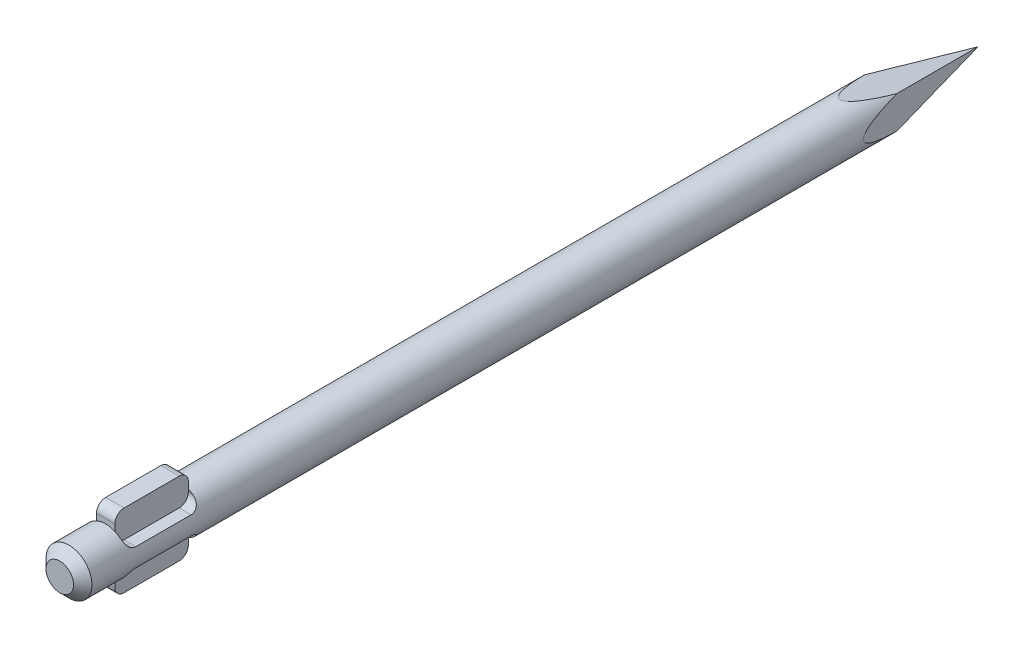
from build123d import *

# Parameters (mm, degrees)
SKETCH1_R           = 2.5
BOSS_EXTRUDE1_DEPTH = 100
CUT_EXTRUDE1_DEPTH  = 2.5
BOSS_EXTRUDE2_DEPTH = 1
CHAMFER1_SIZE       = 1
CUT_EXTRUDE2_DEPTH  = 2.5
CUT_EXTRUDE3_DEPTH  = 2.5


with BuildPart() as part:
    # Sketch1 → Boss-Extrude1 (new body)
    with BuildSketch(Plane.XY):
        Circle(SKETCH1_R)
    extrude(amount=BOSS_EXTRUDE1_DEPTH)

    # Sketch2 → Cut-Extrude1 (cut, symmetric)
    with BuildSketch(Plane(origin=(0, 0, 0), x_dir=(0, 0, -1), z_dir=(1, 0, 0))):
        with BuildLine():
            Line((-94, 4), (-88, 4))
            ThreePointArc((-88, 4), (-87.292893219, 3.707106781), (-87, 3))
            Line((-87, 3), (-87, 2))
            ThreePointArc((-87, 2), (-87.292893219, 1.292893219), (-88, 1))
            Line((-88, 1), (-94, 1))
            ThreePointArc((-94, 1), (-94.707106781, 1.292893219), (-95, 2))
            Line((-95, 2), (-95, 3))
            ThreePointArc((-95, 3), (-94.707106781, 3.707106781), (-94, 4))
        make_face()
        with BuildLine():
            Line((-95, -3), (-95, -2))
            ThreePointArc((-95, -2), (-94.707106781, -1.292893219), (-94, -1))
            Line((-94, -1), (-88, -1))
            ThreePointArc((-88, -1), (-87.292893219, -1.292893219), (-87, -2))
            Line((-87, -2), (-87, -3))
            ThreePointArc((-87, -3), (-87.292893219, -3.707106781), (-88, -4))
            Line((-88, -4), (-94, -4))
            ThreePointArc((-94, -4), (-94.707106781, -3.707106781), (-95, -3))
        make_face()
    extrude(amount=CUT_EXTRUDE1_DEPTH, both=True, mode=Mode.SUBTRACT)

    # Sketch2_2 → Boss-Extrude2 (add, symmetric)
    with BuildSketch(Plane(origin=(0, 0, 0), x_dir=(0, 0, -1), z_dir=(1, 0, 0))):
        with BuildLine():
            Line((-94, 4), (-88, 4))
            ThreePointArc((-88, 4), (-87.292893219, 3.707106781), (-87, 3))
            Line((-87, 3), (-87, 2))
            ThreePointArc((-87, 2), (-87.292893219, 1.292893219), (-88, 1))
            Line((-88, 1), (-94, 1))
            ThreePointArc((-94, 1), (-94.707106781, 1.292893219), (-95, 2))
            Line((-95, 2), (-95, 3))
            ThreePointArc((-95, 3), (-94.707106781, 3.707106781), (-94, 4))
        make_face()
        with BuildLine():
            Line((-95, -3), (-95, -2))
            ThreePointArc((-95, -2), (-94.707106781, -1.292893219), (-94, -1))
            Line((-94, -1), (-88, -1))
            ThreePointArc((-88, -1), (-87.292893219, -1.292893219), (-87, -2))
            Line((-87, -2), (-87, -3))
            ThreePointArc((-87, -3), (-87.292893219, -3.707106781), (-88, -4))
            Line((-88, -4), (-94, -4))
            ThreePointArc((-94, -4), (-94.707106781, -3.707106781), (-95, -3))
        make_face()
    extrude(amount=BOSS_EXTRUDE2_DEPTH, both=True)

    # Chamfer1
    chamfer1_edges = [part.edges().sort_by_distance(p)[0] for p in [
        (-2.5, 0, 100),
    ]]
    chamfer(chamfer1_edges, length=CHAMFER1_SIZE)

    # Sketch3 → Cut-Extrude2 (cut, symmetric)
    with BuildSketch(Plane(origin=(0, 0, 0), x_dir=(0, 0, -1), z_dir=(1, 0, 0))):
        Polygon((0, -2.5), (0, 0), (-15, -2.5), align=None)
        Polygon((-15, 2.5), (0, 0), (0, 2.5), align=None)
    extrude(amount=CUT_EXTRUDE2_DEPTH, both=True, mode=Mode.SUBTRACT)

    # Sketch4 → Cut-Extrude3 (cut, symmetric)
    with BuildSketch(Plane(origin=(0, 0, 0), x_dir=(1, 0, 0), z_dir=(0, 1, 0))):
        Polygon((2.5, 0), (0, 0), (2.5, -15), align=None)
        Polygon((-2.5, -15), (0, 0), (-2.5, 0), align=None)
    extrude(amount=CUT_EXTRUDE3_DEPTH, both=True, mode=Mode.SUBTRACT)


solid = part.part
